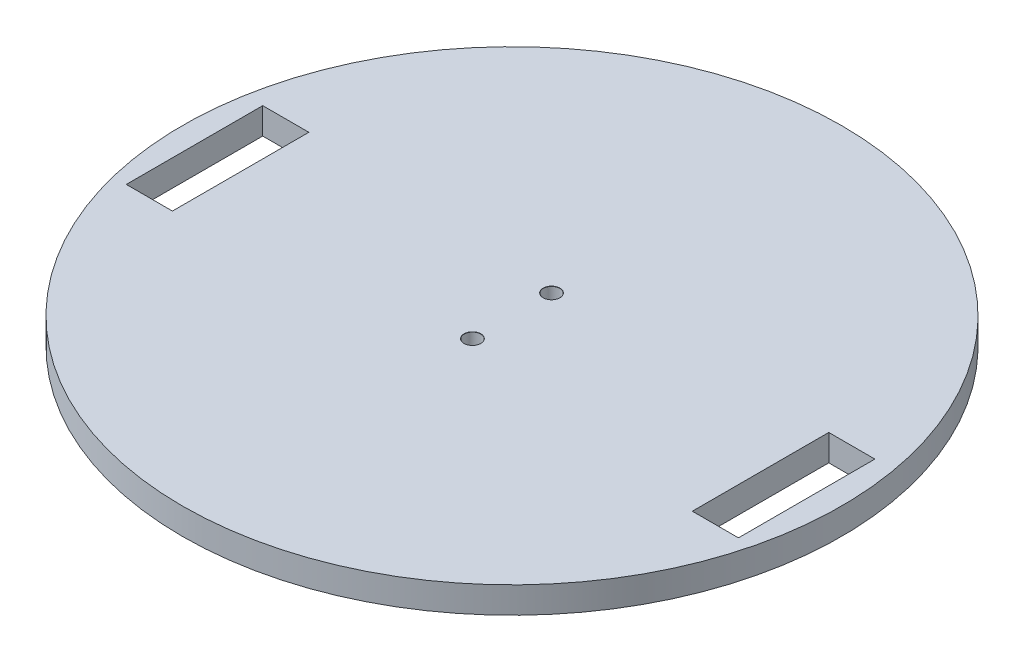
from build123d import *

# Parameters (mm, degrees)
SKETCH2_R                             = 50
SKETCH2_W                             = 7
SKETCH2_H                             = 20.7
BOSS_EXTRUDE2_DEPTH                   = 4
TAP_DRILL_FOR_M3X0_5_TAP1_D           = 2.5
TAP_DRILL_FOR_M3X0_5_TAP1_CSINK_D     = 2.55
TAP_DRILL_FOR_M3X0_5_TAP1_CSINK_ANGLE = 90
SKETCH5_W                             = 7
SKETCH5_H                             = 20.7
BOSS_EXTRUDE4_DEPTH                   = 4
SKETCH5_4_W                           = 7
SKETCH5_4_H                           = 20.7
CUT_EXTRUDE1_DEPTH                    = 10


with BuildPart() as part:
    # Sketch2 → Boss-Extrude2 (new body)
    with BuildSketch(Plane(origin=(0, 0, 0), x_dir=(1, 0, 0), z_dir=(0, 1, 0))):
        Circle(SKETCH2_R)
        with Locations((-29.901246403, -1.65)):
            Rectangle(SKETCH2_W, SKETCH2_H, mode=Mode.SUBTRACT)
        with Locations((29.901246403, -1.65)):
            Rectangle(SKETCH2_W, SKETCH2_H, mode=Mode.SUBTRACT)
    extrude(amount=BOSS_EXTRUDE2_DEPTH)

    # Tap Drill for M3x0.5 Tap1 (through all)
    with Locations(Plane(origin=(0, 4, 0), x_dir=(1, 0, 0), z_dir=(0, 1, 0))):
        with Locations((0, 6), (0, -6)):
            CounterSinkHole(TAP_DRILL_FOR_M3X0_5_TAP1_D / 2, TAP_DRILL_FOR_M3X0_5_TAP1_CSINK_D / 2, counter_sink_angle=TAP_DRILL_FOR_M3X0_5_TAP1_CSINK_ANGLE)

    # Sketch5 → Boss-Extrude4 (add)
    with BuildSketch(Plane.XZ):
        with Locations((-29.901246403, 1.65)):
            Rectangle(SKETCH5_W, SKETCH5_H)
        with Locations((29.901246403, 1.65)):
            Rectangle(SKETCH5_W, SKETCH5_H)
    extrude(amount=-BOSS_EXTRUDE4_DEPTH)

    # Sketch5_4 → Cut-Extrude1 (cut)
    with BuildSketch(Plane.XZ):
        with Locations((-43.019801761, 1.65)):
            Rectangle(SKETCH5_4_W, SKETCH5_4_H)
        with Locations((42.856988689, 1.65)):
            Rectangle(SKETCH5_4_W, SKETCH5_4_H)
    extrude(amount=-CUT_EXTRUDE1_DEPTH, mode=Mode.SUBTRACT)


solid = part.part
